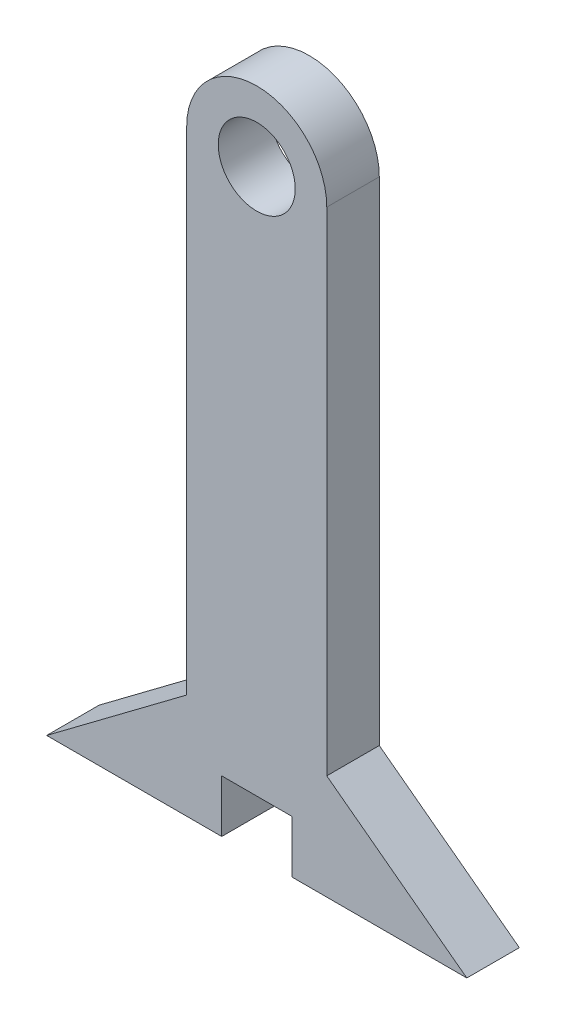
from build123d import *

# Parameters (mm, degrees)
CROQUIS1_R              = 11
SALIENTE_EXTRUIR1_DEPTH = 7.5
CROQUIS2_W              = 20
CROQUIS2_H              = 30
CORTAR_EXTRUIR1_DEPTH   = 16
SALIENTE_EXTRUIR2_DEPTH = 15


with BuildPart() as part:
    # Croquis1 → Saliente-Extruir1 (new body, symmetric)
    with BuildSketch(Plane.XY):
        with BuildLine():
            Line((0, 0), (40, 0))
            Line((40, 0), (40, 170.675))
            ThreePointArc((40, 170.675), (20, 190.675), (0, 170.675))
            Line((0, 170.675), (0, 0))
        make_face()
        with Locations((20, 170.675)):
            Circle(CROQUIS1_R, mode=Mode.SUBTRACT)
    extrude(amount=SALIENTE_EXTRUIR1_DEPTH, both=True)

    # Croquis2 → Cortar-Extruir1 (cut, through all)
    with BuildSketch(Plane.XY.offset(7.5)):
        with Locations((20, 0)):
            Rectangle(CROQUIS2_W, CROQUIS2_H)
    extrude(amount=-CORTAR_EXTRUIR1_DEPTH, mode=Mode.SUBTRACT)

    # Croquis3 → Saliente-Extruir2 (add)
    with BuildSketch(Plane.XY.offset(7.5)):
        Polygon((40, 30), (80, 0), (40, 0), align=None)
        Polygon((0, 30), (0, 0), (-40, 0), align=None)
    extrude(amount=-SALIENTE_EXTRUIR2_DEPTH)


solid = part.part
